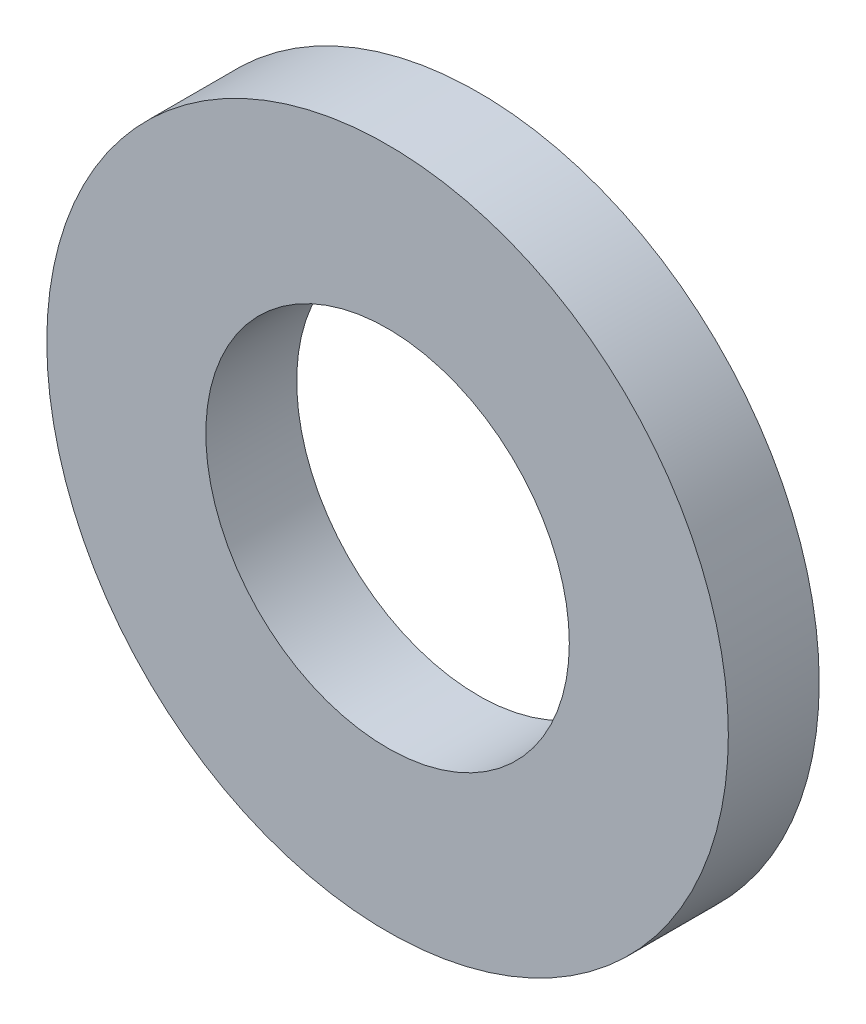
from build123d import *

# Parameters (mm, degrees)
SKETCH1_R          = 6
SKETCH1_R_2        = 3.2
BASE_EXTRUDE_DEPTH = 1.6


with BuildPart() as part:
    # Sketch1 → Base-Extrude (new body)
    with BuildSketch(Plane.XY):
        Circle(SKETCH1_R)
        Circle(SKETCH1_R_2, mode=Mode.SUBTRACT)
    extrude(amount=-BASE_EXTRUDE_DEPTH)


solid = part.part
